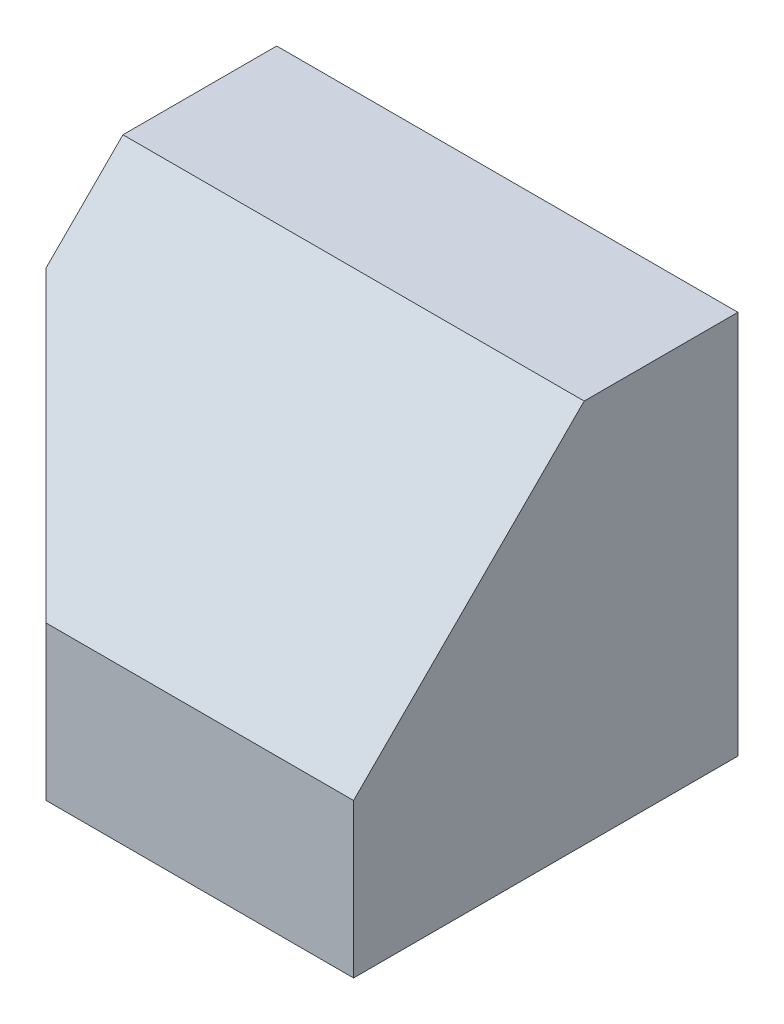
from build123d import *

# Parameters (mm, degrees)
SKETCH1_W           = 60
SKETCH1_H           = 50
BOSS_EXTRUDE1_DEPTH = 50
CUT_EXTRUDE1_DEPTH  = 50
SKETCH3_W           = 60
SKETCH3_H           = 30
CUT_EXTRUDE2_DEPTH  = 30
BOSS_EXTRUDE2_DEPTH = 30
SKETCH9_W           = 60
SKETCH9_H           = 50
CUT_EXTRUDE3_DEPTH  = 10
SKETCH10_W          = 60
SKETCH10_H          = 30
CUT_EXTRUDE4_DEPTH  = 10
BOSS_EXTRUDE7_DEPTH = 30
CUT_EXTRUDE10_DEPTH = 30
SKETCH20_W          = 60
SKETCH20_H          = 42.426406872
CUT_EXTRUDE11_DEPTH = 30


with BuildPart() as part:
    # Sketch1 → Boss-Extrude1 (new body)
    with BuildSketch(Plane.XY):
        with Locations((30, 25)):
            Rectangle(SKETCH1_W, SKETCH1_H)
    extrude(amount=BOSS_EXTRUDE1_DEPTH)

    # Sketch2 → Cut-Extrude1 (cut)
    with BuildSketch(Plane.XZ):
        Polygon((0, 30), (20, 50), (0, 50), align=None)
    extrude(amount=-CUT_EXTRUDE1_DEPTH, mode=Mode.SUBTRACT)

    # Sketch3 → Cut-Extrude2 (cut)
    with BuildSketch(Plane.XY.offset(50)):
        with Locations((30, 35)):
            Rectangle(SKETCH3_W, SKETCH3_H)
    extrude(amount=-CUT_EXTRUDE2_DEPTH, mode=Mode.SUBTRACT)

    # Sketch4 → Boss-Extrude2 (add)
    with BuildSketch(Plane(origin=(0, 35, 35), x_dir=(1, 0, 0), z_dir=(0, 0.707106781, 0.707106781))):
        Polygon((60, -21.213203436), (60, 21.213203436), (0, 21.213203436), (20, -21.213203436), align=None)
    extrude(amount=-BOSS_EXTRUDE2_DEPTH)

    # Sketch9 → Cut-Extrude3 (cut)
    with BuildSketch(Plane(origin=(0, 0, 0), x_dir=(-1, 0, 0), z_dir=(0, 0, -1))):
        with Locations((-30, 25)):
            Rectangle(SKETCH9_W, SKETCH9_H)
    extrude(amount=CUT_EXTRUDE3_DEPTH, mode=Mode.SUBTRACT)

    # Sketch10 → Cut-Extrude4 (cut)
    with BuildSketch(Plane.XZ):
        with Locations((30, 15)):
            Rectangle(SKETCH10_W, SKETCH10_H)
    extrude(amount=CUT_EXTRUDE4_DEPTH, mode=Mode.SUBTRACT)

    # Sketch18 → Boss-Extrude7 (add)
    with BuildSketch(Plane(origin=(0, 20, 0), x_dir=(1, 0, 0), z_dir=(0, 1, 0))):
        Polygon((10, -20), (0, -20), (0, -30), (20, -50), align=None)
    extrude(amount=BOSS_EXTRUDE7_DEPTH)

    # Sketch19 → Cut-Extrude10 (cut)
    with BuildSketch(Plane(origin=(3, 0, -1), x_dir=(-0.316227766, 0, -0.948683298), z_dir=(0.948683298, 0, -0.316227766))):
        Polygon((-22.135943621, 50), (-53.758720223, 20), (-53.758720223, 50), align=None)
    extrude(amount=-CUT_EXTRUDE10_DEPTH, mode=Mode.SUBTRACT)

    # Sketch20 → Cut-Extrude11 (cut)
    with BuildSketch(Plane(origin=(0, 35, 35), x_dir=(1, 0, 0), z_dir=(0, 0.707106781, 0.707106781))):
        with Locations((30, 0)):
            Rectangle(SKETCH20_W, SKETCH20_H)
    extrude(amount=CUT_EXTRUDE11_DEPTH, mode=Mode.SUBTRACT)


solid = part.part
